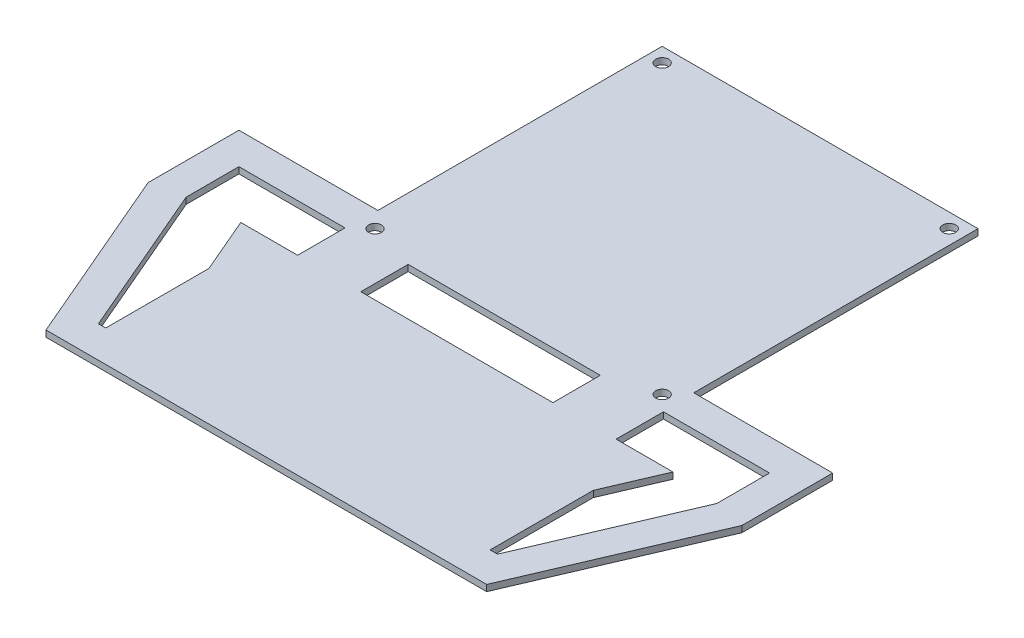
from build123d import *

# Parameters (mm, degrees)
SALIENTE_EXTRUIR1_DEPTH    = 2
CROQUIS2_R                 = 2.05
CORTAR_EXTRUIR1_DEPTH      = 3
CROQUIS7_W                 = 60.830944854
CROQUIS7_H                 = 15
CORTAR_EXTRUIR2_DEPTH      = 1
CORTAR_EXTRUIR2_DEPTH_BACK = 5


with BuildPart() as part:
    # Croquis1 → Saliente-Extruir1 (new body)
    with BuildSketch(Plane(origin=(0, 0, 0), x_dir=(1, 0, 0), z_dir=(0, 1, 0))):
        Polygon((94, -40), (50, -40), (50, 50), (-50, 50), (-50, -40), (-94, -40), (-94, -68.768453788), (-69.76, -125.32), (69.76, -125.32), (94, -68.768453788), align=None)
    extrude(amount=SALIENTE_EXTRUIR1_DEPTH)

    # Croquis2 → Cortar-Extruir1 (cut, through all)
    with BuildSketch(Plane(origin=(0, 2, 0), x_dir=(1, 0, 0), z_dir=(0, 1, 0))):
        with Locations((-45.45, -45.45)):
            Circle(CROQUIS2_R)
        with Locations((45.45, -45.45)):
            Circle(CROQUIS2_R)
        with Locations((-45.45, 45.45)):
            Circle(CROQUIS2_R)
        with Locations((45.45, 45.45)):
            Circle(CROQUIS2_R)
    extrude(amount=-CORTAR_EXTRUIR1_DEPTH, mode=Mode.SUBTRACT)

    # Croquis7 → Cortar-Extruir2 (cut, two sides)
    with BuildSketch(Plane(origin=(0, 2, 0), x_dir=(1, 0, 0), z_dir=(0, 1, 0))) as cortar_extruir2_sk:
        Polygon((-60.845769586, -115.32), (-60.845769586, -82.66), (-68.415472427, -65), (-50.415472427, -65), (-50.415472427, -50), (-84, -50), (-84, -66.715594747), (-63.166426698, -115.32), align=None)
        with Locations((0, -57.5)):
            Rectangle(CROQUIS7_W, CROQUIS7_H)
        Polygon((84, -50), (50.415472427, -50), (50.415472427, -65), (68.415472427, -65), (60.845769586, -82.66), (60.845769586, -115.32), (63.166426698, -115.32), (84, -66.715594747), align=None)
    extrude(amount=CORTAR_EXTRUIR2_DEPTH, mode=Mode.SUBTRACT)
    extrude(cortar_extruir2_sk.sketch, amount=-CORTAR_EXTRUIR2_DEPTH_BACK, mode=Mode.SUBTRACT)


solid = part.part
